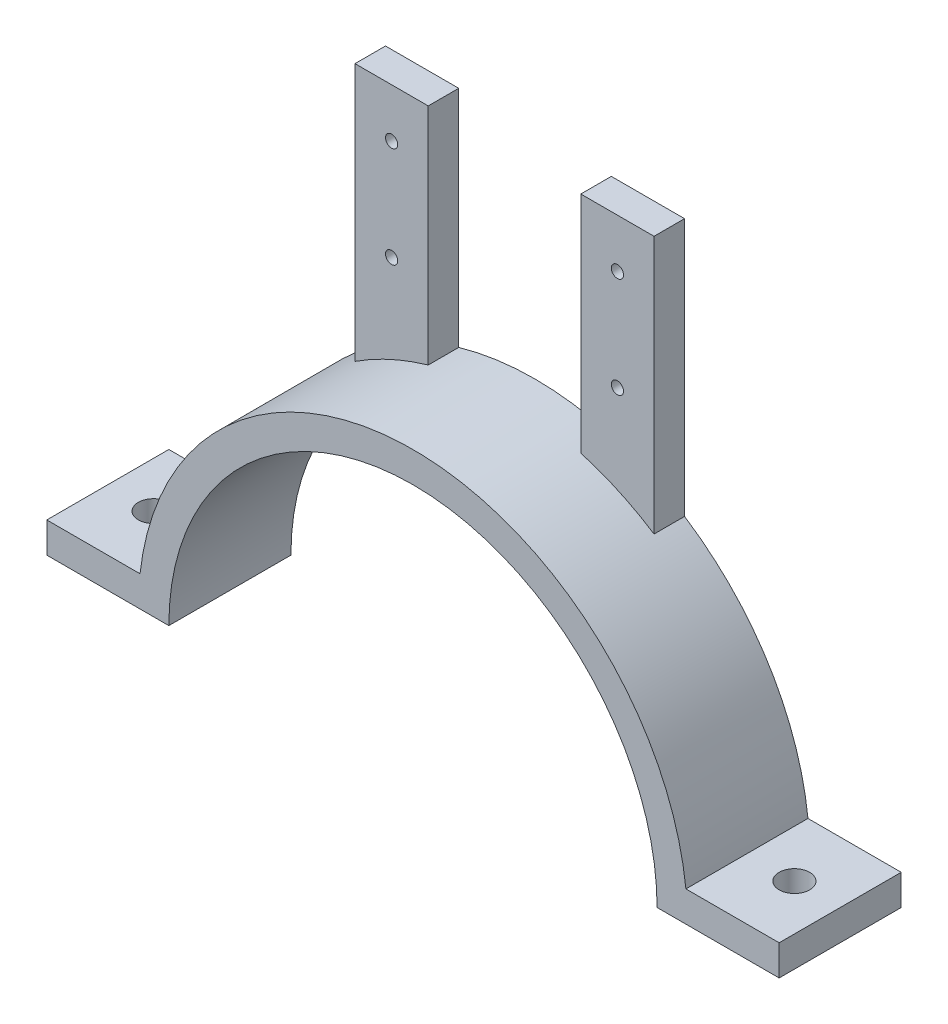
from build123d import *

# Parameters (mm, degrees)
BOSS_EXTRUDE1_DEPTH = 20
F_3DSKETCH3_R       = 1
BOSS_EXTRUDE2_DEPTH = 5
CUT_EXTRUDE1_DEPTH  = 2.5
SKETCH3_R           = 2.5
CUT_EXTRUDE2_DEPTH  = 99.107084352


with BuildPart() as part:
    # Sketch1 → Boss-Extrude1 (new body)
    with BuildSketch(Plane.XY):
        with BuildLine():
            Line((-45, 0), (-40, 0))
            ThreePointArc((-40, 0), (0, 40), (40, 0))
            Line((40, 0), (45, 0))
            Line((45, 0), (60, 0))
            Line((60, 0), (60, 5))
            Line((60, 5), (44.72135955, 5))
            ThreePointArc((44.72135955, 5), (0, 45), (-44.72135955, 5))
            Line((-44.72135955, 5), (-60, 5))
            Line((-60, 5), (-60, 0))
            Line((-60, 0), (-45, 0))
        make_face()
    extrude(amount=BOSS_EXTRUDE1_DEPTH)

    # 3DSketch3 → Boss-Extrude2 (add)
    with BuildSketch(Plane(origin=(-24.5, 37.7458607, 0), x_dir=(0.7573108303632157, 0.6530545966568009, 0), z_dir=(0, 0, -1))):
        with BuildLine():
            Line((0, 0), (27.594259898, -31.999517319))
            Line((27.594259898, -31.999517319), (36.681989862, -24.16286216))
            Line((36.681989862, -24.16286216), (12.668546171, 3.684183209))
            ThreePointArc((12.668546171, 3.684183209), (6.470025326, 1.375289757), (0, 0))
        make_face()
        with Locations(Location((26.913688106, -22.022703097, 0), (0, 0, 40.772303251))):
            Circle(F_3DSKETCH3_R, mode=Mode.SUBTRACT)
        with Locations(Location((16.138287262, -9.527074396, 0), (0, 0, 40.772303251))):
            Circle(F_3DSKETCH3_R, mode=Mode.SUBTRACT)
        with BuildLine():
            Line((31.60131693, 20.010548126), (55.614760621, -7.836497243))
            Line((55.614760621, -7.836497243), (64.702307458, 0))
            Line((64.702307458, 0), (37.10815006, 31.999398456))
            ThreePointArc((37.10815006, 31.999398456), (34.796480727, 25.802065738), (31.60131693, 20.010548126))
        make_face()
        with Locations(Location((54.93418883, 2.14031698, 0), (0, 0, 40.772303251))):
            Circle(F_3DSKETCH3_R, mode=Mode.SUBTRACT)
        with Locations(Location((44.158787985, 14.635945681, 0), (0, 0, 40.772303251))):
            Circle(F_3DSKETCH3_R, mode=Mode.SUBTRACT)
    extrude(amount=-BOSS_EXTRUDE2_DEPTH)

    # Sketch2 → Cut-Extrude1 (cut)
    with BuildSketch(Plane(origin=(0, 0, 0), x_dir=(-1, 0, 0), z_dir=(0, 0, -1))):
        Polygon((-16.19, 55.5), (-17.345, 57.500518683), (-19.655, 57.500518683), (-20.81, 55.5), (-19.655, 53.499481317), (-17.345, 53.499481317), align=None)
        Polygon((-16.19, 72), (-17.345, 74.000518683), (-19.655, 74.000518683), (-20.81, 72), (-19.655, 69.999481317), (-17.345, 69.999481317), align=None)
        Polygon((20.81, 72), (19.655, 74.000518683), (17.345, 74.000518683), (16.19, 72), (17.345, 69.999481317), (19.655, 69.999481317), align=None)
        Polygon((20.81, 55.5), (19.655, 57.500518683), (17.345, 57.500518683), (16.19, 55.5), (17.345, 53.499481317), (19.655, 53.499481317), align=None)
    extrude(amount=-CUT_EXTRUDE1_DEPTH, mode=Mode.SUBTRACT)

    # Sketch3 → Cut-Extrude2 (cut, through all)
    with BuildSketch(Plane(origin=(0, 5, 0), x_dir=(1, 0, 0), z_dir=(0, 1, 0))):
        with Locations(Location((-52.5, -10, 0), (0, 0, 270))):
            Circle(SKETCH3_R)
        with Locations(Location((52.5, -10, 0), (0, 0, 270))):
            Circle(SKETCH3_R)
    extrude(amount=-CUT_EXTRUDE2_DEPTH, mode=Mode.SUBTRACT)


solid = part.part
